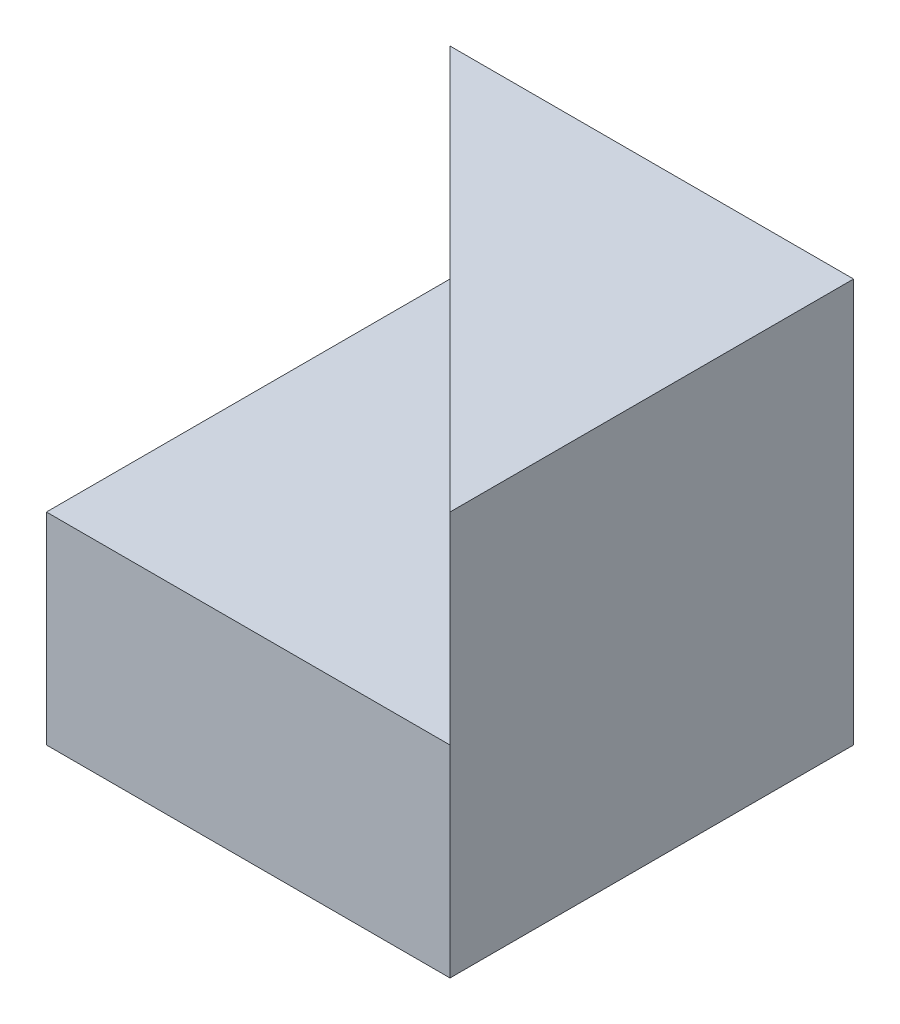
from build123d import *

# Parameters (mm, degrees)
SKETCH1_W           = 40
SKETCH1_H           = 40
BOSS_EXTRUDE1_DEPTH = 40
CUT_EXTRUDE2_DEPTH  = 20


with BuildPart() as part:
    # Sketch1 → Boss-Extrude1 (new body)
    with BuildSketch(Plane.XY):
        with Locations((20, 20)):
            Rectangle(SKETCH1_W, SKETCH1_H)
    extrude(amount=BOSS_EXTRUDE1_DEPTH)

    # Sketch4 → Cut-Extrude2 (cut)
    with BuildSketch(Plane(origin=(0, 40, 0), x_dir=(1, 0, 0), z_dir=(0, 1, 0))):
        Polygon((0, 0), (40, -40), (0, -40), align=None)
    extrude(amount=-CUT_EXTRUDE2_DEPTH, mode=Mode.SUBTRACT)


solid = part.part
